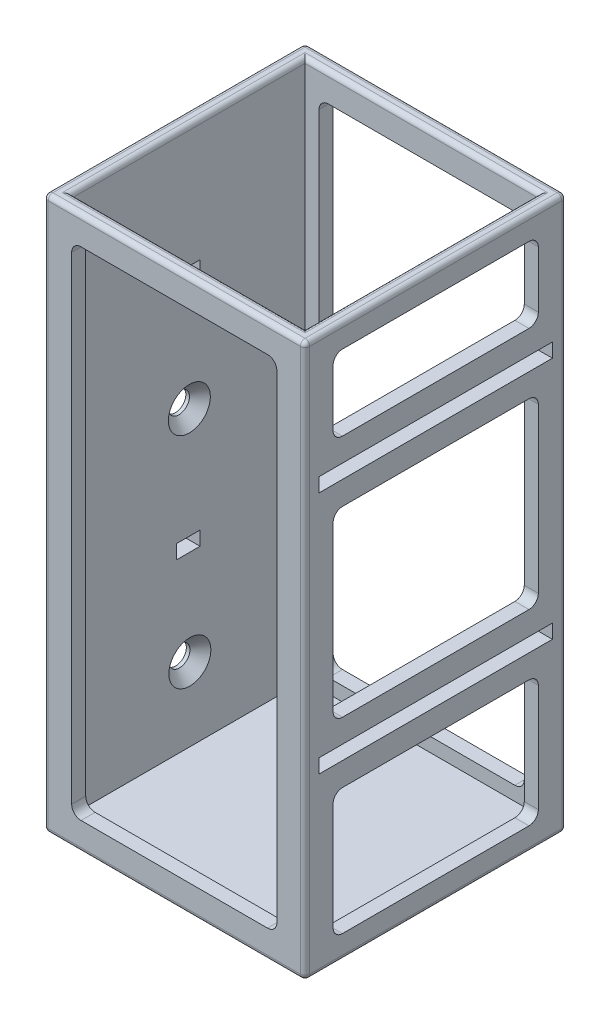
from build123d import *

# Parameters (mm, degrees)
SKETCH1_W                    = 49.788
SKETCH1_H                    = 49.788
BOSS_EXTRUDE1_DEPTH          = 3
SKETCH1_3_W                  = 55.788
SKETCH1_3_H                  = 55.788
SKETCH1_3_W_2                = 49.788
SKETCH1_3_H_2                = 49.788
BOSS_EXTRUDE2_DEPTH          = 118
SKETCH2_W                    = 49.788
SKETCH2_H                    = 3
SKETCH2_W_2                  = 43.788
SKETCH2_H_2                  = 38.949
SKETCH2_H_3                  = 26.974
SKETCH2_H_4                  = 16.077
CUT_EXTRUDE1_DEPTH           = 3
FILLET1_R                    = 2
SKETCH3_W                    = 43.788
SKETCH3_H                    = 106
CUT_EXTRUDE2_DEPTH           = 56
FILLET2_R                    = 2
SKETCH4_W                    = 5
SKETCH4_H                    = 3
CUT_EXTRUDE3_DEPTH           = 3
CSK_FOR_M4_SFHCS1_AT_2_COUNT = 2
CSK_FOR_M4_SFHCS1_AT_2_PITCH = 46.834641181
CSK_FOR_M4_SFHCS1_AT_3_COUNT = 2
CSK_FOR_M4_SFHCS1_AT_3_PITCH = 46.834641181
FILLET3_R                    = 1


with BuildPart() as part:
    # Sketch1 → Boss-Extrude1 (new body)
    with BuildSketch(Plane(origin=(0, 0, 0), x_dir=(1, 0, 0), z_dir=(0, 1, 0))):
        Rectangle(SKETCH1_W, SKETCH1_H)
    extrude(amount=BOSS_EXTRUDE1_DEPTH)

    # Sketch1_3 → Boss-Extrude2 (add)
    with BuildSketch(Plane(origin=(0, 0, 0), x_dir=(1, 0, 0), z_dir=(0, 1, 0))):
        Rectangle(SKETCH1_3_W, SKETCH1_3_H)
        Rectangle(SKETCH1_3_W_2, SKETCH1_3_H_2, mode=Mode.SUBTRACT)
    extrude(amount=BOSS_EXTRUDE2_DEPTH)

    # Sketch2 → Cut-Extrude1 (cut)
    with BuildSketch(Plane(origin=(27.894, 0, 0), x_dir=(0, 0, -1), z_dir=(1, 0, 0))):
        with Locations((0, 90.423)):
            Rectangle(SKETCH2_W, SKETCH2_H)
        with Locations((0, 38.474)):
            Rectangle(SKETCH2_W, SKETCH2_H)
        with Locations((0, 64.4485)):
            Rectangle(SKETCH2_W_2, SKETCH2_H_2)
        with Locations((0, 18.487)):
            Rectangle(SKETCH2_W_2, SKETCH2_H_3)
        with Locations((0, 104.9615)):
            Rectangle(SKETCH2_W_2, SKETCH2_H_4)
    extrude(amount=-CUT_EXTRUDE1_DEPTH, mode=Mode.SUBTRACT)

    # Fillet1
    fillet1_edges = [part.edges().sort_by_distance(p)[0] for p in [
        (26.394, 5, -21.894),
        (26.394, 31.974, -21.894),
        (26.394, 31.974, 21.894),
        (26.394, 5, 21.894),
        (26.394, 44.974, -21.894),
        (26.394, 83.923, -21.894),
        (26.394, 83.923, 21.894),
        (26.394, 44.974, 21.894),
        (26.394, 96.923, 21.894),
        (26.394, 113, 21.894),
        (26.394, 113, -21.894),
        (26.394, 96.923, -21.894),
    ]]
    fillet(fillet1_edges, radius=FILLET1_R)

    # Sketch3 → Cut-Extrude2 (cut)
    with BuildSketch(Plane(origin=(0, 0, -27.894), x_dir=(-1, 0, 0), z_dir=(0, 0, -1))):
        with Locations((0, 59)):
            Rectangle(SKETCH3_W, SKETCH3_H)
    extrude(amount=-CUT_EXTRUDE2_DEPTH, mode=Mode.SUBTRACT)

    # Fillet2
    fillet2_edges = [part.edges().sort_by_distance(p)[0] for p in [
        (21.894, 112, 26.394),
        (-21.894, 112, 26.394),
        (-21.894, 6, 26.394),
        (21.894, 6, 26.394),
        (21.894, 6, -26.394),
        (21.894, 112, -26.394),
        (-21.894, 112, -26.394),
        (-21.894, 6, -26.394),
    ]]
    fillet(fillet2_edges, radius=FILLET2_R)

    # Sketch4 → Cut-Extrude3 (cut)
    with BuildSketch(Plane.ZY.offset(27.894)):
        with Locations((0, 90.423)):
            Rectangle(SKETCH4_W, SKETCH4_H)
        with Locations((0, 40.474)):
            Rectangle(SKETCH4_W, SKETCH4_H)
    extrude(amount=-CUT_EXTRUDE3_DEPTH, mode=Mode.SUBTRACT)

    # Sketch7 → CSK for M4 SFHCS1 (revolve, cut)
    with BuildSketch(Plane(origin=(-24.894, 65.538290214, -0.216772751), x_dir=(0, 0, -1), z_dir=(0, 1, 0))):
        Polygon((0, 0), (0, 3), (2.25, 3), (2.25, 2.23), (4.48, 0), align=None)
    csk_for_m4_sfhcs1 = revolve(axis=Axis((-18.544, 65.538290214, -0.216772751), (-1, 0, 0)), mode=Mode.SUBTRACT)

    # CSK for M4 SFHCS1 at 2: CSK for M4 SFHCS1 ×2
    with Locations(*[Vector(0, -0.999997358387733, -0.002298525082753328) * (i * CSK_FOR_M4_SFHCS1_AT_2_PITCH) for i in range(1, CSK_FOR_M4_SFHCS1_AT_2_COUNT)]):
        add(csk_for_m4_sfhcs1, mode=Mode.SUBTRACT)

    # CSK for M4 SFHCS1 at 3: CSK for M4 SFHCS1 ×2
    with Locations(*[Vector(0, -0.999997358387733, -0.002298525082753328) * (i * CSK_FOR_M4_SFHCS1_AT_3_PITCH) for i in range(1, CSK_FOR_M4_SFHCS1_AT_3_COUNT)]):
        add(csk_for_m4_sfhcs1, mode=Mode.SUBTRACT)

    # Fillet3
    fillet3_edges = [part.edges().sort_by_distance(p)[0] for p in [
        (0, 118, -27.894),
        (-27.894, 118, 0),
        (-24.894, 118, 0),
        (0, 118, -24.894),
        (0, 118, 27.894),
        (0, 118, 24.894),
        (24.894, 118, 0),
        (27.894, 118, 0),
        (0, 0, -27.894),
        (27.894, 0, 0),
        (0, 0, 27.894),
        (-27.894, 59, 27.894),
        (27.894, 59, 27.894),
        (-27.894, 59, -27.894),
        (27.894, 59, -27.894),
        (-27.894, 0, 0),
    ]]
    fillet(fillet3_edges, radius=FILLET3_R)


solid = part.part
